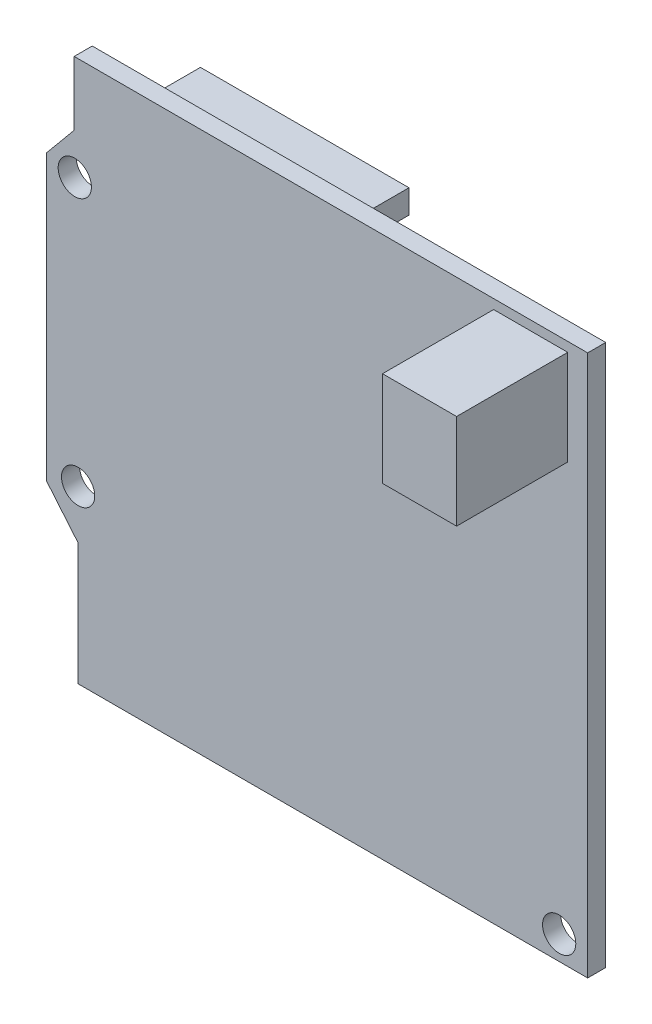
from build123d import *

# Parameters (mm, degrees)
SKETCH1_W                      = 57
SKETCH1_H                      = 57
BOSS_EXTRUDE1_DEPTH            = 10.4
SKETCH2_W                      = 7.8
SKETCH2_H                      = 10
BOSS_EXTRUDE3_DEPTH            = 11.7
F_3_5_3_5_DIAMETER_HOLE1_D     = 3.5
F_3_5_3_5_DIAMETER_HOLE1_DEPTH = 10.4
CUT_EXTRUDE1_REACH             = 12.4
SKETCH7_W                      = 21.956188663
SKETCH7_H                      = 2.5
SKETCH7_W_2                    = 42
CUT_EXTRUDE2_DEPTH             = 8.5


with BuildPart() as part:
    # Sketch1 → Boss-Extrude1 (new body)
    with BuildSketch(Plane.XY):
        Rectangle(SKETCH1_W, SKETCH1_H)
    extrude(amount=BOSS_EXTRUDE1_DEPTH)

    # Sketch2 → Boss-Extrude3 (add)
    with BuildSketch(Plane.XY.offset(10.4)):
        with Locations((22.5, 22.5)):
            Rectangle(SKETCH2_W, SKETCH2_H)
    extrude(amount=BOSS_EXTRUDE3_DEPTH)

    # Ø3.5 (3.5) Diameter Hole1
    with Locations(Plane.XY.offset(10.4)):
        with Locations((-25.5, 17.5), (-25.148622044, -10.5), (25.5, -26)):
            Hole(F_3_5_3_5_DIAMETER_HOLE1_D / 2, depth=F_3_5_3_5_DIAMETER_HOLE1_DEPTH)

    # Sketch6 → Cut-Extrude1 (cut, up to next)
    with BuildSketch(Plane.XY.offset(10.4), mode=Mode.PRIVATE) as cut_extrude1_sk1:
        Polygon((-25.562379587, 28.5), (-25.562379587, 21.769543161), (-28.5, 18.222574402), (-28.5, 28.5), align=None)
    cut_extrude1_tool1 = extrude(cut_extrude1_sk1.sketch, amount=-CUT_EXTRUDE1_REACH, mode=Mode.PRIVATE) & part.part
    add(cut_extrude1_tool1.solids().sort_by_distance((-27.133296, 24.186386, 10.4))[0], mode=Mode.SUBTRACT)
    # Sketch6 → Cut-Extrude1 (cut, up to next)
    with BuildSketch(Plane.XY.offset(10.4), mode=Mode.PRIVATE) as cut_extrude1_sk2:
        Polygon((-25.169304276, -15.622117115), (-28.5, -11.638473715), (-28.5, -28.5), (-25.169304276, -28.5), align=None)
    cut_extrude1_tool2 = extrude(cut_extrude1_sk2.sketch, amount=-CUT_EXTRUDE1_REACH, mode=Mode.PRIVATE) & part.part
    add(cut_extrude1_tool2.solids().sort_by_distance((-26.909011, -21.02068, 10.4))[0], mode=Mode.SUBTRACT)

    # Sketch7 → Cut-Extrude2 (cut)
    with BuildSketch(Plane(origin=(0, 0, 0), x_dir=(-1, 0, 0), z_dir=(0, 0, -1))):
        Polygon((-28.5, -28.5), (25.169304276, -28.5), (25.169304276, -15.622117115), (28.5, -11.638473715), (28.5, 18.222574402), (25.562379587, 21.769543161), (25.562379587, 28.5), (-28.5, 28.5), align=None)
        with Locations((11.691209945, 22.5)):
            Rectangle(SKETCH7_W, SKETCH7_H, mode=Mode.SUBTRACT)
        with Locations((1.669304276, -26.25)):
            Rectangle(SKETCH7_W_2, SKETCH7_H, mode=Mode.SUBTRACT)
    extrude(amount=-CUT_EXTRUDE2_DEPTH, mode=Mode.SUBTRACT)


solid = part.part
